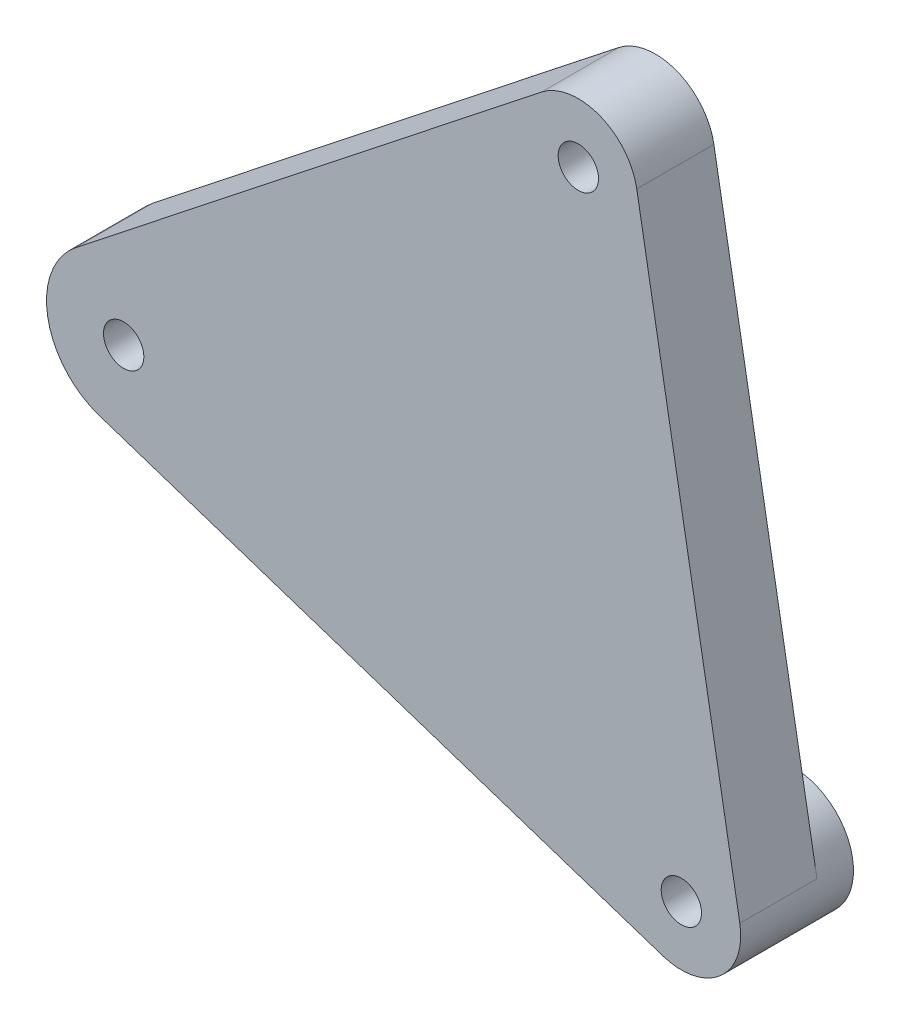
from build123d import *

# Parameters (mm, degrees)
EXTRUDE_START   = 0.25
SKETCH_1_R      = 1.7
EXTRUDE_1_DEPTH = 6.5
SKETCH_2_R      = 5
SKETCH_2_R_2    = 1.7
EXTRUDE_2_DEPTH = 3


with BuildPart() as part:
    # 草图1 → 凸台-拉伸1 (new body)
    with BuildSketch(Plane.XY.offset(EXTRUDE_START)):
        with BuildLine():
            Line((198.226260921, 33.007621373), (206.908669804, -16.232766278))
            ThreePointArc((206.908669804, -16.232766278), (205.255667217, -20.882583864), (200.416253934, -21.848658507))
            Line((200.416253934, -21.848658507), (152.961109764, -6.171946743))
            ThreePointArc((152.961109764, -6.171946743), (148.598749605, -1.128713155), (150.97313978, 5.10239128))
            Line((150.97313978, 5.10239128), (190.204637372, 36.064296853))
            ThreePointArc((190.204637372, 36.064296853), (195.08261531, 36.811660465), (198.226260921, 33.007621373))
        make_face()
        with Locations((201.984631039, -17.101007166)):
            Circle(SKETCH_1_R, mode=Mode.SUBTRACT)
        with Locations((155, 0)):
            Circle(SKETCH_1_R, mode=Mode.SUBTRACT)
        with Locations((193.302222156, 32.139380484)):
            Circle(SKETCH_1_R, mode=Mode.SUBTRACT)
    extrude(amount=EXTRUDE_1_DEPTH)

    # 草图2 → 凸台-拉伸2 (add)
    with BuildSketch(Plane(origin=(0, 0, 0.25), x_dir=(-1, 0, 0), z_dir=(0, 0, -1))):
        with Locations((-201.984631039, -17.101007166)):
            Circle(SKETCH_2_R)
        with Locations((-201.984631039, -17.101007166)):
            Circle(SKETCH_2_R_2, mode=Mode.SUBTRACT)
    extrude(amount=EXTRUDE_2_DEPTH)


solid = part.part
